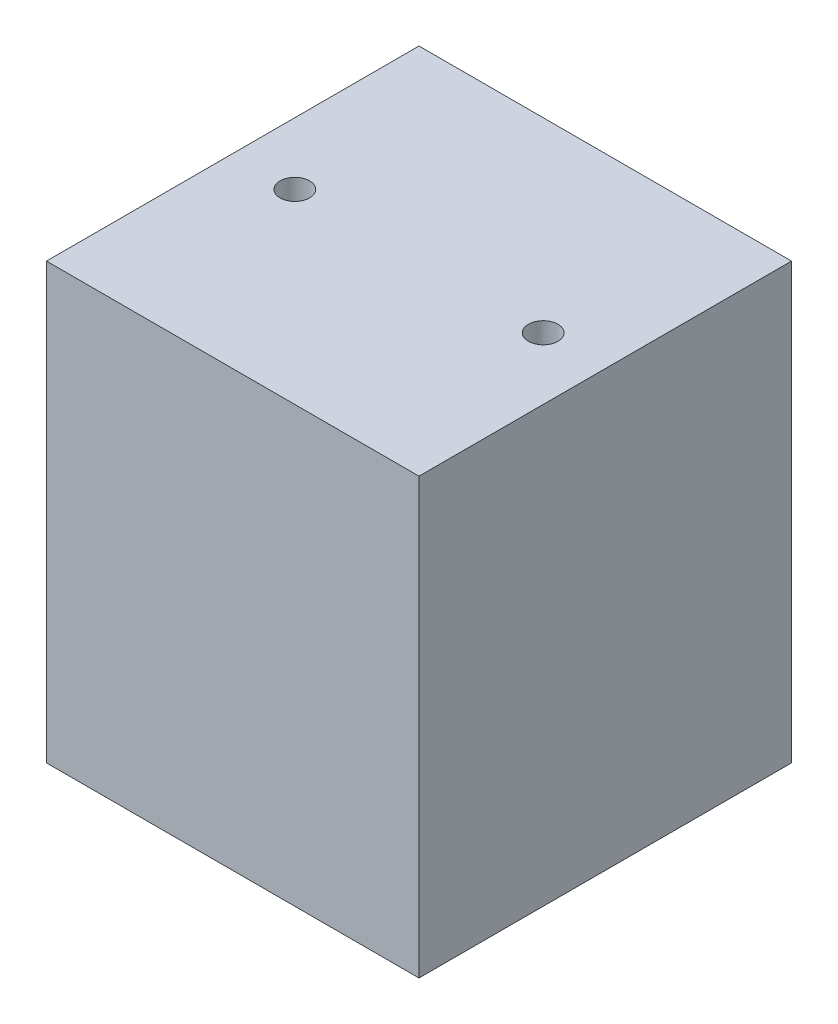
from build123d import *

# Parameters (mm, degrees)
SKETCH1_W                   = 60
SKETCH1_H                   = 60
BOSS_EXTRUDE1_DEPTH         = 70
SKETCH2_R                   = 2.3815
CUT_EXTRUDE1_DEPTH          = 71
F_1_4_20_TAPPED_HOLE1_D     = 5.1054
F_1_4_20_TAPPED_HOLE1_DEPTH = 19.05
F_1_4_20_TAPPED_HOLE1_TIP   = 1.533816902


with BuildPart() as part:
    # Sketch1 → Boss-Extrude1 (new body)
    with BuildSketch(Plane(origin=(0, 0, 0), x_dir=(1, 0, 0), z_dir=(0, 1, 0))):
        with Locations((30, 30)):
            Rectangle(SKETCH1_W, SKETCH1_H)
    extrude(amount=BOSS_EXTRUDE1_DEPTH)

    # Sketch2 → Cut-Extrude1 (cut, through all)
    with BuildSketch(Plane.XZ):
        with Locations(Location((10, -30, 0), (0, 0, 270))):  # turned: the seam where the file's is
            Circle(SKETCH2_R)
        with Locations(Location((50, -30, 0), (0, 0, 270))):  # turned: the seam where the file's is
            Circle(SKETCH2_R)
    extrude(amount=-CUT_EXTRUDE1_DEPTH, mode=Mode.SUBTRACT)

    # 1/4-20 Tapped Hole1
    with Locations(Plane(origin=(30, 0, -10), x_dir=(0, 0, -1), z_dir=(0, -1, 0))):
        with Locations((0, 0), (40, 0)):
            Hole(F_1_4_20_TAPPED_HOLE1_D / 2, depth=F_1_4_20_TAPPED_HOLE1_DEPTH)
            with Locations((0, 0, -(F_1_4_20_TAPPED_HOLE1_DEPTH + F_1_4_20_TAPPED_HOLE1_TIP / 2))):  # 118° drill point
                Cone(0, F_1_4_20_TAPPED_HOLE1_D / 2, F_1_4_20_TAPPED_HOLE1_TIP, mode=Mode.SUBTRACT)


solid = part.part
